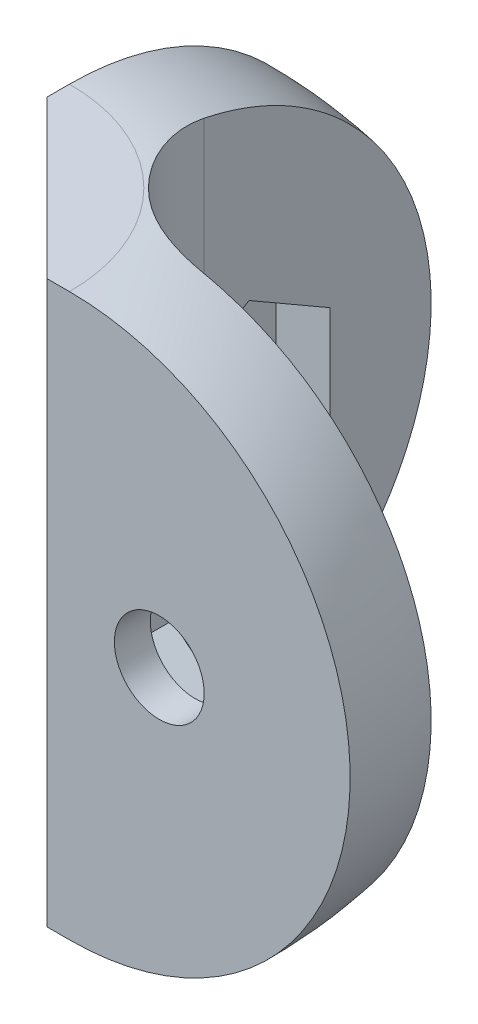
from build123d import *

# Parameters (mm, degrees)
BOSS_EXTRUDE1_DEPTH = 25
SKETCH3_R           = 2
CUT_EXTRUDE1_DEPTH  = 21.5000001
SKETCH4_R           = 2
CUT_EXTRUDE2_DEPTH  = 21.5000001
CUT_EXTRUDE3_START  = -1.6
CUT_EXTRUDE3_DEPTH  = 19.9000001
CUT_EXTRUDE4_START  = -1.6
CUT_EXTRUDE4_DEPTH  = 19.9000001
CHAMFER1_SIZE       = 7


with BuildPart() as part:
    # Sketch1 → Boss-Extrude1 (new body)
    with BuildSketch(Plane(origin=(0, 0, 0), x_dir=(1, 0, 0), z_dir=(0, 1, 0))):
        with BuildLine():
            Line((0, 0), (0, 25))
            Line((0, 25), (4, 25))
            Line((4, 25), (4, 10))
            ThreePointArc((4, 10), (5.757359313, 5.757359313), (10, 4))
            Line((10, 4), (25, 4))
            Line((25, 4), (25, 0))
            Line((25, 0), (0, 0))
        make_face()
    extrude(amount=BOSS_EXTRUDE1_DEPTH)

    # Sketch2 → Cut-Revolve2 (revolve, cut)
    with BuildSketch(Plane.XY):
        with BuildLine():
            Line((8, 0), (0, 0))
            Line((0, 0), (0, -0.947269394))
            Line((0, -0.947269394), (27.823952472, -0.947269394))
            Line((27.823952472, -0.947269394), (27.823952472, 28.581077379))
            Line((27.823952472, 28.581077379), (0, 28.581077379))
            Line((0, 28.581077379), (0, 25))
            Line((0, 25), (8, 25))
            ThreePointArc((8, 25), (20.5, 12.5), (8, 0))
        make_face()
    revolve(axis=Axis((0, 25, 0), (0, 1, 0)), mode=Mode.SUBTRACT)

    # Sketch3 → Cut-Extrude1 (cut, through all)
    with BuildSketch(Plane.XY):
        with Locations((12, 12.5)):
            Circle(SKETCH3_R)
    extrude(amount=-CUT_EXTRUDE1_DEPTH, mode=Mode.SUBTRACT)

    # Sketch4 → Cut-Extrude2 (cut, through all)
    with BuildSketch(Plane.ZY):
        with Locations((-12, 12.5)):
            Circle(SKETCH4_R)
    extrude(amount=-CUT_EXTRUDE2_DEPTH, mode=Mode.SUBTRACT)

    # Sketch5 → Cut-Extrude3 (cut, through all)
    with BuildSketch(Plane.ZY.offset(CUT_EXTRUDE3_START)):
        Polygon((-8.4, 14.578460969), (-12, 16.656921938), (-15.6, 14.578460969), (-15.6, 10.421539031), (-12, 8.343078062), (-8.4, 10.421539031), align=None)
    extrude(amount=-CUT_EXTRUDE3_DEPTH, mode=Mode.SUBTRACT)

    # Sketch6 → Cut-Extrude4 (cut, through all)
    with BuildSketch(Plane.XY.offset(CUT_EXTRUDE4_START)):
        Polygon((12, 8.343078062), (15.6, 10.421539031), (15.6, 14.578460969), (12, 16.656921938), (8.4, 14.578460969), (8.4, 10.421539031), align=None)
    extrude(amount=-CUT_EXTRUDE4_DEPTH, mode=Mode.SUBTRACT)

    # Chamfer1
    chamfer1_edges = [part.edges().sort_by_distance(p)[0] for p in [
        (0, 12.5, 0),
    ]]
    chamfer(chamfer1_edges, length=CHAMFER1_SIZE)


solid = part.part
